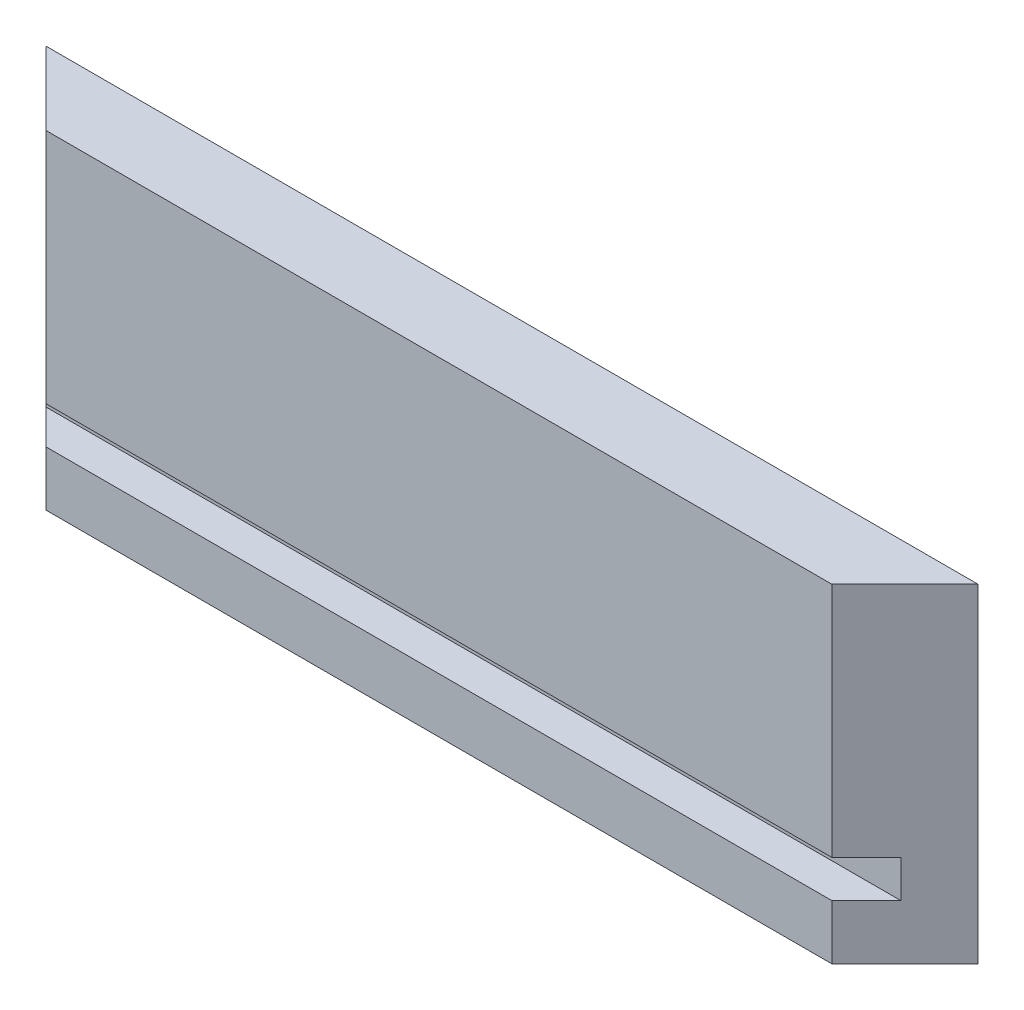
from build123d import *

# Parameters (mm, degrees)
BOSS_EXTRUDE1_DEPTH     = 28.575
SKETCH2_W               = 2.9972
SKETCH2_H               = 3.2512
CUT_EXTRUDE1_DEPTH      = 82.0006
CUT_EXTRUDE1_DEPTH_BACK = 1


with BuildPart() as part:
    # Sketch1 → Boss-Extrude1 (new body)
    with BuildSketch(Plane(origin=(0, 0, 0), x_dir=(1, 0, 0), z_dir=(0, 1, 0))):
        Polygon((0, 0), (81.0006, 0), (74.6506, -6.35), (6.35, -6.35), align=None)
    extrude(amount=BOSS_EXTRUDE1_DEPTH)

    # Sketch2 → Cut-Extrude1 (cut, two sides)
    with BuildSketch(Plane(origin=(0, 0, 0), x_dir=(0, 0, -1), z_dir=(1, 0, 0))) as cut_extrude1_sk:
        with Locations((-4.8514, 6.3881)):
            Rectangle(SKETCH2_W, SKETCH2_H)
    extrude(amount=CUT_EXTRUDE1_DEPTH, mode=Mode.SUBTRACT)
    extrude(cut_extrude1_sk.sketch, amount=-CUT_EXTRUDE1_DEPTH_BACK, mode=Mode.SUBTRACT)


solid = part.part
